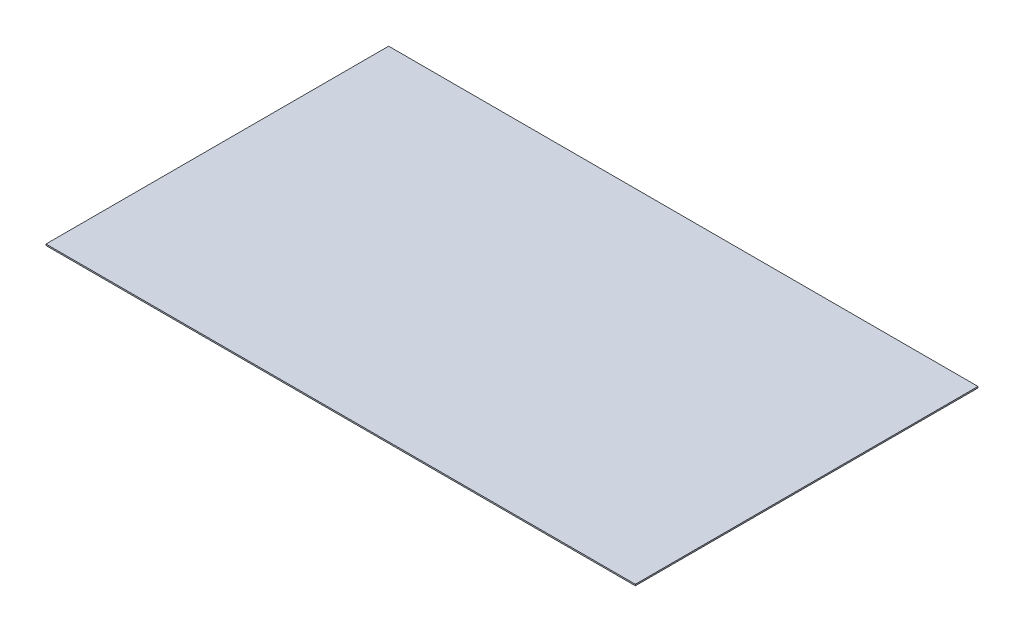
from build123d import *

# Parameters (mm, degrees)
SKETCH_1_W      = 430
SKETCH_1_H      = 250
EXTRUDE_2_DEPTH = 1


with BuildPart() as part:
    # 草图1 → 凸台-拉伸2 (new body)
    with BuildSketch(Plane(origin=(0, 0, 0), x_dir=(1, 0, 0), z_dir=(0, 1, 0))):
        with Locations((215, 125)):
            Rectangle(SKETCH_1_W, SKETCH_1_H)
    extrude(amount=EXTRUDE_2_DEPTH)


solid = part.part
